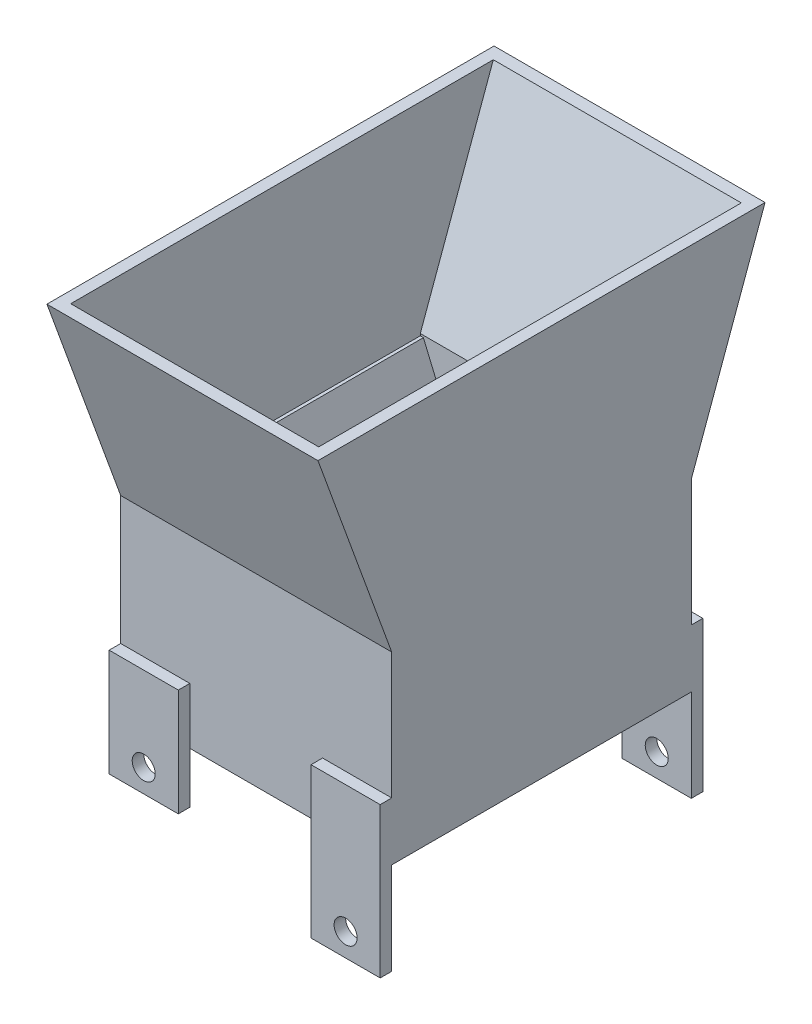
from build123d import *

# Parameters (mm, degrees)
BOSS_EXTRUDE2_DEPTH = 74.676
SHELL1_T            = -3.175
BOSS_EXTRUDE3_REACH = 101.695
SKETCH7_W           = 19.05
SKETCH7_H           = 41.37312771
SKETCH7_R           = 3.175
SKETCH7_H_2         = 29.549685012
BOSS_EXTRUDE4_DEPTH = 3.175


with BuildPart() as part:
    # Sketch4 → Boss-Extrude2 (new body)
    with BuildSketch(Plane(origin=(0, 0, 0), x_dir=(0, 0, -1), z_dir=(1, 0, 0))):
        Polygon((-44.915630504, 37.043578511), (78.274369496, 37.043578511), (57.954369496, -18.785162652), (57.954369496, -69.585162652), (-24.595630504, -69.585162652), (-24.595630504, -18.785162652), align=None)
    extrude(amount=BOSS_EXTRUDE2_DEPTH)

    # Shell1
    shell1_openings = [part.faces().sort_by_distance(p)[0] for p in [
        (37.338, 37.043578511, -16.679369496),
        (37.338, -69.585162652, -16.679369496),
    ]]
    offset(amount=SHELL1_T, openings=shell1_openings, kind=Kind.INTERSECTION)

    # Sketch6 → Boss-Extrude3 (add, up to next)
    with BuildSketch(Plane(origin=(0, 0, 21.420630504), x_dir=(-1, 0, 0), z_dir=(0, 0, -1)), mode=Mode.PRIVATE) as boss_extrude3_sk1:
        Polygon((-4.030024393, -18.785162652), (-25.4, -69.585162652), (-22.225, -69.585162652), (0, -18.785162652), align=None)
    boss_extrude3_tool1 = extrude(boss_extrude3_sk1.sketch, amount=BOSS_EXTRUDE3_REACH, mode=Mode.PRIVATE) - part.part
    add(boss_extrude3_tool1.solids().sort_by_distance((12.482636, -43.180418, 21.420631))[0])

    # Sketch7 → Boss-Extrude4 (add)
    with BuildSketch(Plane(origin=(0, 0, -57.954369496), x_dir=(-1, 0, 0), z_dir=(0, 0, -1))):
        with Locations((-65.151, -74.298598797)):
            Rectangle(SKETCH7_W, SKETCH7_H)
        with Locations((-65.151, -88.635162652)):
            Circle(SKETCH7_R, mode=Mode.SUBTRACT)
        with Locations((-9.525, -68.867228229)):
            Rectangle(SKETCH7_W, SKETCH7_H_2)
        with Locations((-9.525, -77.292070735)):
            Circle(SKETCH7_R, mode=Mode.SUBTRACT)
    boss_extrude4 = extrude(amount=BOSS_EXTRUDE4_DEPTH)

    # Mirror1: Boss-Extrude4 across plane
    add(boss_extrude4.mirror(Plane(origin=(0, 0, -16.679369496), x_dir=(1, 0, 0), z_dir=(0, 0, -1))))


solid = part.part
